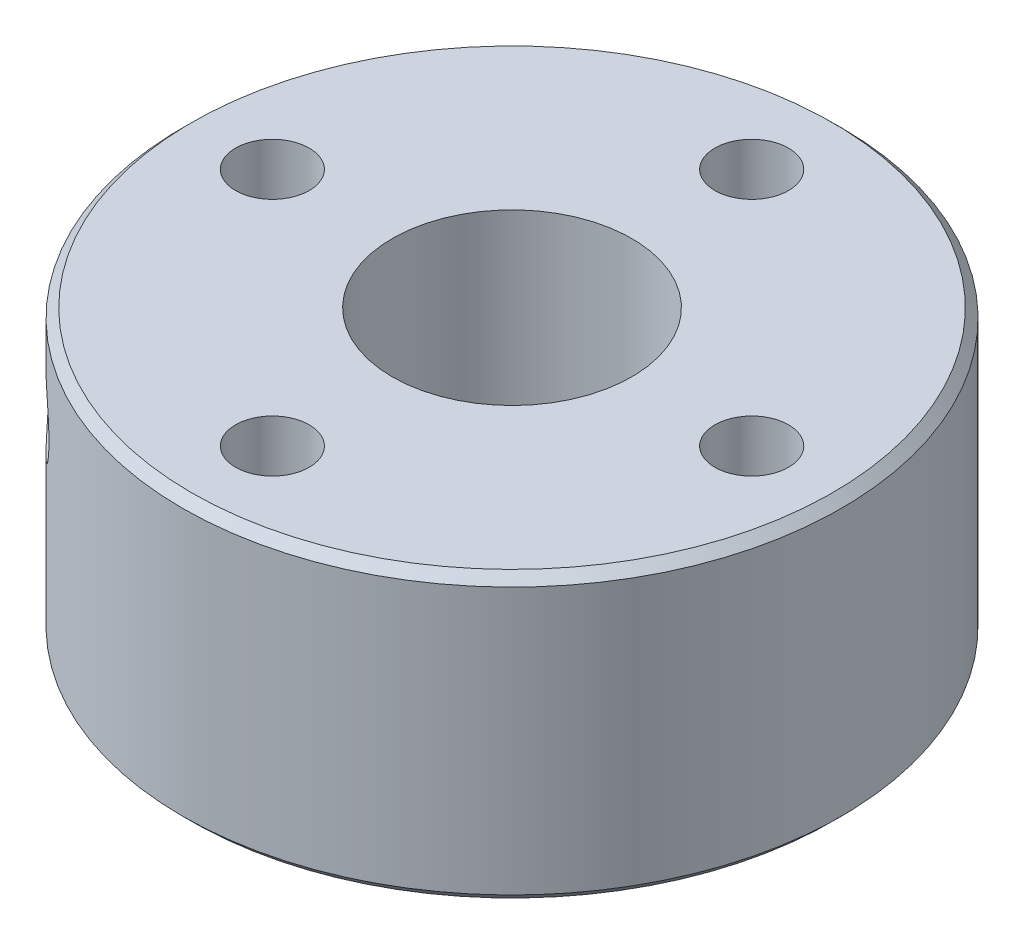
from build123d import *

# Parameters (mm, degrees)
SCHIZZO1_W                                           = 11
SCHIZZO1_H                                           = 9.5
SCHIZZO2_R                                           = 4.75
ESTRUSIONE_ESTRUSIONE1_DEPTH                         = 3.5
FORO_PER_VITE_M2_1_D                                 = 2.459
FORO_PER_VITE_M2_1_DEPTH                             = 13
FORO_LAMATO_PER_VITE_M3_5_A_TESTA_ESAGON_D           = 4
FORO_LAMATO_PER_VITE_M3_5_A_TESTA_ESAGON_DEPTH       = 13
FORO_LAMATO_PER_VITE_M3_5_A_TESTA_ESAGON_CBORE_D     = 8
FORO_LAMATO_PER_VITE_M3_5_A_TESTA_ESAGON_CBORE_DEPTH = 8.5
SCHIZZO7_W                                           = 1.2295
SCHIZZO7_H                                           = 11.749995321
SMUSSO1_SIZE                                         = 0.3


with BuildPart() as part:
    # Schizzo1 → Rivoluzione1 (revolve)
    with BuildSketch(Plane(origin=(0, 0, 0), x_dir=(-1, 0, 0), z_dir=(0, 0, -1))):
        with Locations((-5.5, 8.25)):
            Rectangle(SCHIZZO1_W, SCHIZZO1_H)
    revolve(axis=Axis((0, 3.5, 0), (0, 1, 0)))

    # Schizzo2 → Estrusione-Estrusione1 (add)
    with BuildSketch(Plane.XZ.offset(-3.5)):
        Circle(SCHIZZO2_R)
    extrude(amount=ESTRUSIONE_ESTRUSIONE1_DEPTH)

    # Foro per Vite M2-1
    with Locations(Plane(origin=(0, 13, 0), x_dir=(1, 0, 0), z_dir=(0, 1, 0))):
        with Locations((0, 8), (-8, 0), (0, -8), (8, 0)):
            Hole(FORO_PER_VITE_M2_1_D / 2, depth=FORO_PER_VITE_M2_1_DEPTH)

    # Foro lamato per Vite M3.5 a testa esagonale-1
    with Locations(Plane(origin=(0, 13, 0), x_dir=(1, 0, 0), z_dir=(0, 1, 0))):
        with Locations((0, 0)):
            CounterBoreHole(FORO_LAMATO_PER_VITE_M3_5_A_TESTA_ESAGON_D / 2, FORO_LAMATO_PER_VITE_M3_5_A_TESTA_ESAGON_CBORE_D / 2, FORO_LAMATO_PER_VITE_M3_5_A_TESTA_ESAGON_CBORE_DEPTH, depth=FORO_LAMATO_PER_VITE_M3_5_A_TESTA_ESAGON_DEPTH)

    # Schizzo7 → Foro per Vite M2-2 (revolve, cut)
    with BuildSketch(Plane(origin=(-2.69149863, 10, 2.69149863), x_dir=(-0.707106781, 0, -0.707106781), z_dir=(0, 1, 0))):
        with Locations((0.61475, 5.874997661)):
            Rectangle(SCHIZZO7_W, SCHIZZO7_H)
    revolve(axis=Axis((1.798629431, 10, -1.798629431), (-0.707106781, 0, 0.707106781)), mode=Mode.SUBTRACT)

    # Smusso1
    smusso1_edges = [part.edges().sort_by_distance(p)[0] for p in [
        (-11, 13, 0),
        (-11, 3.5, 0),
        (-4.75, 0, 0),
    ]]
    chamfer(smusso1_edges, length=SMUSSO1_SIZE)


solid = part.part
